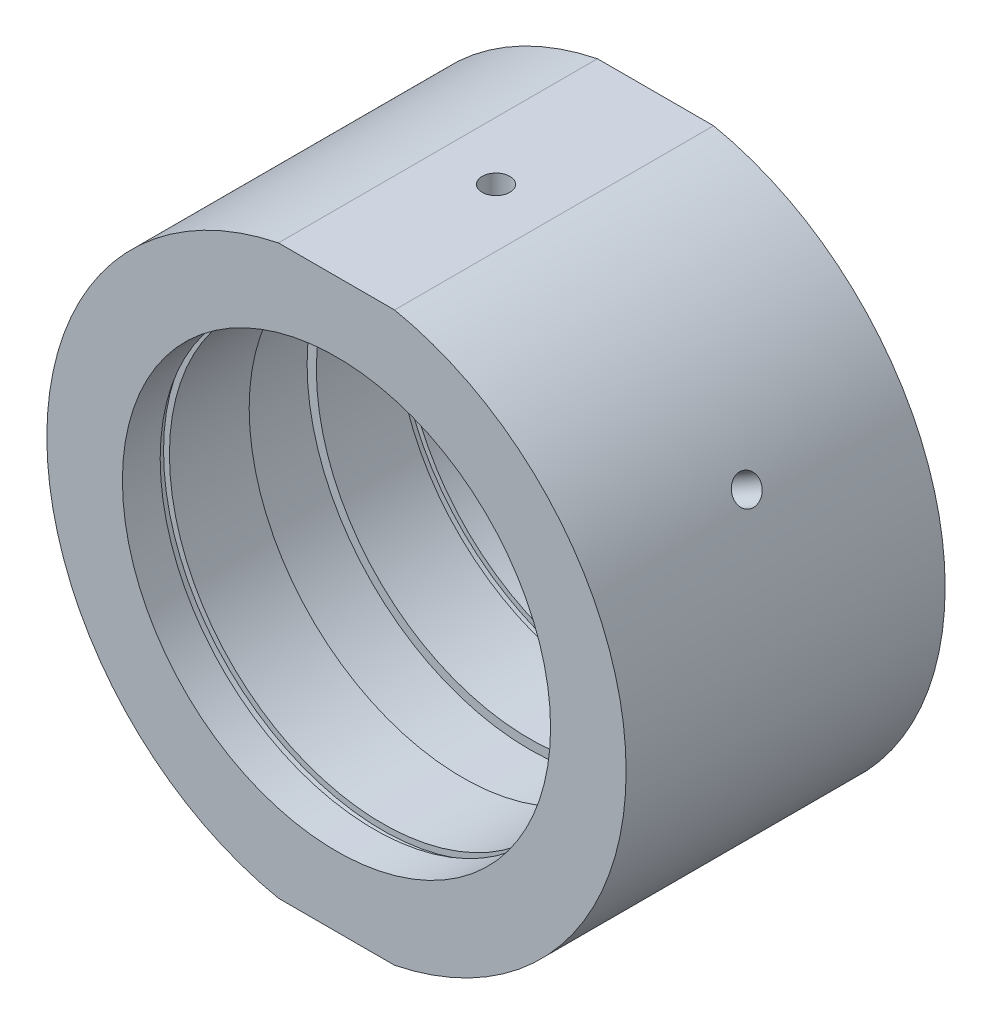
from build123d import *

# Parameters (mm, degrees)
SKETCH_2_W                       = 64.02174429
SKETCH_2_H                       = 9.248919907
CUT_EXTRUDE_1_DEPTH              = 49
HOLE_WIZARD_M4_2_D               = 3.3
HOLE_WIZARD_M4_2_DEPTH           = 5.5
HOLE_WIZARD_M4_2_TIP             = 0.991420021
HOLE_WIZARD_M6_2_D               = 5
HOLE_WIZARD_M6_2_DEPTH           = 5.5
HOLE_WIZARD_M6_2_TIP             = 1.502151548
HOLE_WIZARD_M4_3_D               = 3.3
HOLE_WIZARD_M4_3_DEPTH           = 10.1
HOLE_WIZARD_M4_3_TIP             = 0.991420021
HOLE_WIZARD_M4_3_ON_FACE_2_D     = 3.3
HOLE_WIZARD_M4_3_ON_FACE_2_DEPTH = 10.1
HOLE_WIZARD_M4_3_ON_FACE_2_TIP   = 0.991420021


with BuildPart() as part:
    # 草图1 → 旋转1 (revolve)
    with BuildSketch(Plane(origin=(0, 0, 0), x_dir=(1, 0, 0), z_dir=(0, 1, 0)), mode=Mode.PRIVATE) as revolve_1_sk:
        Polygon((34.5, 19), (34.5, -19), (25.5, -19), (25.5, -14.5), (26.1, -14.5), (26.1, -13.5), (25.4, -13.5), (25.4, -4), (26.5, -4), (26.5, 4), (25.4, 4), (25.4, 13.5), (26.1, 13.5), (26.1, 14.5), (25.5, 14.5), (25.5, 19), align=None)
    revolve(revolve_1_sk.sketch.rotate(Axis((0, 0, -31.9390681), (0, 0, 1)), 180), axis=Axis((0, 0, -31.9390681), (0, 0, 1)))  # turned: the seam where the file's is

    # 草图2 → 切除-拉伸1 (cut)
    with BuildSketch(Plane.XY.offset(19)):
        with Locations((-1.141100508, 38.424459954)):
            Rectangle(SKETCH_2_W, SKETCH_2_H)
        with Locations((-1.141100508, -38.424459954)):
            Rectangle(SKETCH_2_W, SKETCH_2_H)
    extrude(amount=-CUT_EXTRUDE_1_DEPTH, mode=Mode.SUBTRACT)

    # M4 螺纹孔2
    with Locations(Plane(origin=(0, 33.8, 0), x_dir=(1, 0, 0), z_dir=(0, 1, 0))):
        with Locations((0, 0)):
            Hole(HOLE_WIZARD_M4_2_D / 2, depth=HOLE_WIZARD_M4_2_DEPTH)
            with Locations((0, 0, -(HOLE_WIZARD_M4_2_DEPTH + HOLE_WIZARD_M4_2_TIP / 2))):  # 118° drill point
                Cone(0, HOLE_WIZARD_M4_2_D / 2, HOLE_WIZARD_M4_2_TIP, mode=Mode.SUBTRACT)

    # M6 螺纹孔2
    with Locations(Plane(origin=(0, -33.8, 0), x_dir=(-1, 0, 0), z_dir=(0, -1, 0))):
        with Locations((0, 0)):
            Hole(HOLE_WIZARD_M6_2_D / 2, depth=HOLE_WIZARD_M6_2_DEPTH)
            with Locations((0, 0, -(HOLE_WIZARD_M6_2_DEPTH + HOLE_WIZARD_M6_2_TIP / 2))):  # 118° drill point
                Cone(0, HOLE_WIZARD_M6_2_D / 2, HOLE_WIZARD_M6_2_TIP, mode=Mode.SUBTRACT)

    # M4 螺纹孔3
    with Locations(Plane(origin=(29.877876431, 17.25, 0), x_dir=(-0.5, 0.866025404, 0), z_dir=(0.866025404, 0.5, 0))):
        with Locations((0, 0)):
            Hole(HOLE_WIZARD_M4_3_D / 2, depth=HOLE_WIZARD_M4_3_DEPTH)
            with Locations((0, 0, -(HOLE_WIZARD_M4_3_DEPTH + HOLE_WIZARD_M4_3_TIP / 2))):  # 118° drill point
                Cone(0, HOLE_WIZARD_M4_3_D / 2, HOLE_WIZARD_M4_3_TIP, mode=Mode.SUBTRACT)

    # M4 螺纹孔3 on face 2
    with Locations(Plane(origin=(-29.877876431, 17.25, 0), x_dir=(-0.500000175, -0.866025303, 0), z_dir=(-0.866025303, 0.500000175, 0))):
        with Locations((0, 0)):
            Hole(HOLE_WIZARD_M4_3_ON_FACE_2_D / 2, depth=HOLE_WIZARD_M4_3_ON_FACE_2_DEPTH)
            with Locations((0, 0, -(HOLE_WIZARD_M4_3_ON_FACE_2_DEPTH + HOLE_WIZARD_M4_3_ON_FACE_2_TIP / 2))):  # 118° drill point
                Cone(0, HOLE_WIZARD_M4_3_ON_FACE_2_D / 2, HOLE_WIZARD_M4_3_ON_FACE_2_TIP, mode=Mode.SUBTRACT)


solid = part.part
